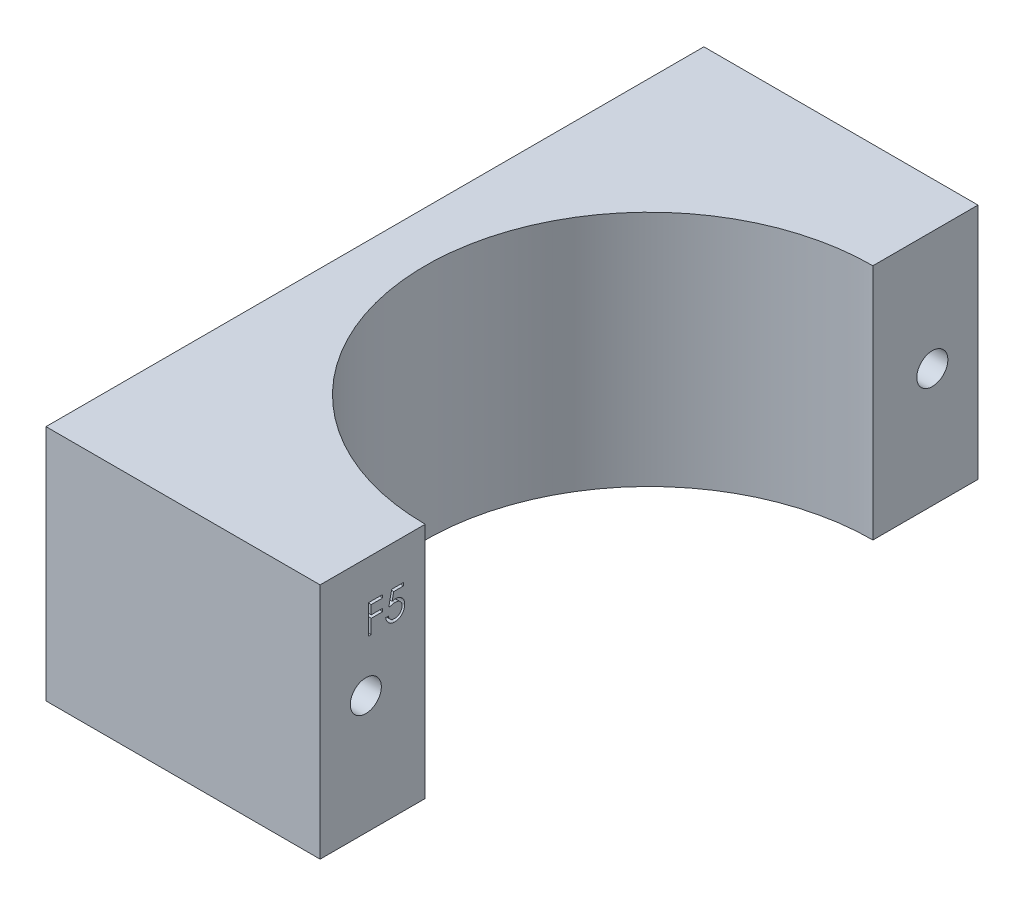
from build123d import *

# Parameters (mm, degrees)
BOSS_EXTRUDE1_DEPTH = 26
SKETCH2_R           = 1.7
CUT_EXTRUDE1_DEPTH  = 31
CUT_EXTRUDE2_DEPTH  = 1


with BuildPart() as part:
    # Sketch1 → Boss-Extrude1 (new body)
    with BuildSketch(Plane(origin=(0, 0, 0), x_dir=(1, 0, 0), z_dir=(0, 1, 0))):
        with BuildLine():
            Line((-46.998275301, 32.528571429), (-46.998275301, -39.471428571))
            Line((-46.998275301, -39.471428571), (-16.998275301, -39.471428571))
            Line((-16.998275301, -39.471428571), (-16.998275301, -27.971428571))
            ThreePointArc((-16.998275301, -27.971428571), (-41.498275301, -3.471428571), (-16.998275301, 21.028571429))
            Line((-16.998275301, 21.028571429), (-16.998275301, 32.528571429))
            Line((-16.998275301, 32.528571429), (-46.998275301, 32.528571429))
        make_face()
    extrude(amount=BOSS_EXTRUDE1_DEPTH)

    # Sketch2 → Cut-Extrude1 (cut, through all)
    with BuildSketch(Plane(origin=(-16.998275301, 0, 0), x_dir=(0, 0, -1), z_dir=(1, 0, 0))):
        with Locations((-34.471428571, 13)):
            Circle(SKETCH2_R)
        with Locations((27.528571429, 13)):
            Circle(SKETCH2_R)
    extrude(amount=-CUT_EXTRUDE1_DEPTH, mode=Mode.SUBTRACT)

    # Sketch3 → Cut-Extrude2 (cut)
    with BuildSketch(Plane(origin=(-16.998275301, 0, 0), x_dir=(0, 0, -1), z_dir=(1, 0, 0))):
        Polygon((-34.164231178, 21.664809495), (-32.617436306, 21.664809495), (-32.617436306, 21.33916847), (-33.87929528, 21.33916847), (-33.87929528, 20.362245393), (-32.617436306, 20.362245393), (-32.617436306, 20.036604367), (-33.87929528, 20.036604367), (-33.87929528, 18.489809495), (-34.164231178, 18.489809495), align=None)
        with BuildLine():
            Line((-30.337949127, 21.664809495), (-30.337949127, 21.33916847))
            Line((-30.337949127, 21.33916847), (-31.417271042, 21.33916847))
            Line((-31.417271042, 21.33916847), (-31.588995801, 20.504077324))
            add(Edge.make_bspline(
                [(-31.588995801, 20.504077324), (-31.555380829, 20.513357642), (-31.490257138, 20.53133679), (-31.394136407, 20.551299168), (-31.302884908, 20.563332821), (-31.243670822, 20.564975938), (-31.215017436, 20.565771034)],
                knots=[0, 0, 0, 0, 0.000104595, 0.000202637, 0.000294305, 0.000380252, 0.000380252, 0.000380252, 0.000380252], degree=3))
            add(Edge.make_bspline(
                [(-31.215017436, 20.565771034), (-31.179562901, 20.565003649), (-31.109850426, 20.56349478), (-31.007852238, 20.54900603), (-30.910485971, 20.526200536), (-30.817955249, 20.494341206), (-30.730088893, 20.453601662), (-30.647695319, 20.402711002), (-30.569537784, 20.343262909), (-30.497018431, 20.27491422), (-30.431228522, 20.199692467), (-30.37338366, 20.118813541), (-30.324250453, 20.033063448), (-30.284734626, 19.941622896), (-30.253180265, 19.845502806), (-30.232178099, 19.743691821), (-30.218192941, 19.637149598), (-30.216630491, 19.564301881), (-30.215833742, 19.527154247)],
                knots=[0, 0, 0, 0, 0.000106308, 0.000209029, 0.000308378, 0.000405929, 0.000502102, 0.000598312, 0.00069588, 0.000796219, 0.000896736, 0.000995218, 0.001094066, 0.001192613, 0.001293582, 0.001396995, 0.001504047, 0.001615439, 0.001615439, 0.001615439, 0.001615439], degree=3))
            add(Edge.make_bspline(
                [(-30.215833742, 19.527154247), (-30.21643706, 19.501280519), (-30.217635543, 19.449882723), (-30.223730262, 19.373551912), (-30.235464805, 19.298837056), (-30.251219812, 19.225728244), (-30.271669005, 19.154363885), (-30.296424075, 19.084539713), (-30.326719043, 19.01669032), (-30.359948934, 18.950173711), (-30.397365381, 18.886493637), (-30.438893027, 18.826940628), (-30.482767437, 18.770621315), (-30.529976408, 18.718139715), (-30.58095874, 18.669840691), (-30.635096995, 18.625437607), (-30.691959176, 18.584179543), (-30.752425003, 18.547741252), (-30.815147113, 18.51421057), (-30.881031281, 18.48670279), (-30.948577774, 18.462109668), (-31.018758768, 18.44250674), (-31.091415298, 18.427146494), (-31.16666713, 18.416713806), (-31.244119595, 18.409115181), (-31.296620499, 18.408639514), (-31.323140433, 18.408399239)],
                knots=[0, 0, 0, 0, 7.7636e-05, 0.000154223, 0.000229512, 0.000304362, 0.000378447, 0.000452077, 0.000526407, 0.000601214, 0.00067506, 0.000747747, 0.00081887, 0.000889121, 0.000959302, 0.001029336, 0.001099058, 0.00116985, 0.001240974, 0.00131221, 0.00138383, 0.001456517, 0.001530612, 0.001606437, 0.001684346, 0.001763871, 0.001763871, 0.001763871, 0.001763871], degree=3))
            add(Edge.make_bspline(
                [(-31.323140433, 18.408399239), (-31.354776297, 18.409025928), (-31.417016122, 18.410258864), (-31.508202636, 18.423157061), (-31.5959366, 18.441630042), (-31.679511763, 18.469421516), (-31.759677124, 18.504244276), (-31.835353446, 18.548255374), (-31.9084744, 18.598129276), (-31.976067462, 18.656985024), (-32.038801936, 18.721315679), (-32.094959984, 18.791127253), (-32.144974014, 18.865267533), (-32.188043113, 18.944096573), (-32.224780604, 19.02740724), (-32.253641343, 19.115511677), (-32.276935279, 19.207949537), (-32.286789954, 19.271588793), (-32.29179528, 19.303912059)],
                knots=[0, 0, 0, 0, 9.4843e-05, 0.000186593, 0.000275792, 0.000363484, 0.000450342, 0.000537514, 0.000625728, 0.000715478, 0.000805885, 0.000894984, 0.00098389, 0.001073836, 0.001164117, 0.001256635, 0.001351658, 0.001449737, 0.001449737, 0.001449737, 0.001449737], degree=3))
            Line((-32.29179528, 19.303912059), (-32.006859383, 19.303912059))
            add(Edge.make_bspline(
                [(-32.006859383, 19.303912059), (-31.999848477, 19.273634849), (-31.986373127, 19.215440369), (-31.956795055, 19.133678367), (-31.920631011, 19.060817357), (-31.877628495, 18.995893521), (-31.826329539, 18.939279645), (-31.767792128, 18.888827024), (-31.702162408, 18.843311014), (-31.629234264, 18.805371789), (-31.552296685, 18.773015134), (-31.471772144, 18.751468954), (-31.389853202, 18.736318858), (-31.334446394, 18.734802333), (-31.306603974, 18.734040265)],
                knots=[0, 0, 0, 0, 9.3172e-05, 0.000179081, 0.000260145, 0.000336703, 0.000411917, 0.000488562, 0.000568128, 0.000650923, 0.00073478, 0.000817953, 0.000900557, 0.000983994, 0.000983994, 0.000983994, 0.000983994], degree=3))
            add(Edge.make_bspline(
                [(-31.306603974, 18.734040265), (-31.279427385, 18.734784827), (-31.22591646, 18.736250878), (-31.14716613, 18.747534839), (-31.07113588, 18.764913493), (-30.998575921, 18.790921147), (-30.928216524, 18.822530284), (-30.861837461, 18.863093246), (-30.797518422, 18.909774834), (-30.737258616, 18.96325692), (-30.682068544, 19.022193714), (-30.633304062, 19.085219635), (-30.592685005, 19.152454203), (-30.558454778, 19.222733421), (-30.532462142, 19.29682754), (-30.513919252, 19.374389321), (-30.503030763, 19.455610338), (-30.501532907, 19.511008927), (-30.500769639, 19.539238582)],
                knots=[0, 0, 0, 0, 8.15e-05, 0.000160473, 0.000238226, 0.000315066, 0.000391338, 0.000469218, 0.000547964, 0.000629516, 0.000710512, 0.000789892, 0.000868102, 0.000945761, 0.001024012, 0.00110315, 0.001184644, 0.001269321, 0.001269321, 0.001269321, 0.001269321], degree=3))
            add(Edge.make_bspline(
                [(-30.500769639, 19.539238582), (-30.501366974, 19.564707299), (-30.502536172, 19.61455869), (-30.512088904, 19.687492256), (-30.528705015, 19.756501373), (-30.551768106, 19.821919285), (-30.581050231, 19.883807694), (-30.616833671, 19.94223047), (-30.659789968, 19.99641759), (-30.708859038, 20.046394406), (-30.762614547, 20.092517971), (-30.82198137, 20.13183725), (-30.885717161, 20.164915232), (-30.953054012, 20.193461202), (-31.025593599, 20.213963307), (-31.101899401, 20.229355603), (-31.182795415, 20.238259539), (-31.238104539, 20.239494967), (-31.266534864, 20.240130008)],
                knots=[0, 0, 0, 0, 7.6388e-05, 0.000149519, 0.000220172, 0.000288967, 0.000357247, 0.000425206, 0.000494043, 0.000564207, 0.000635056, 0.000706145, 0.000777268, 0.000850264, 0.000925136, 0.001002969, 0.001083601, 0.001168886, 0.001168886, 0.001168886, 0.001168886], degree=3))
            add(Edge.make_bspline(
                [(-31.266534864, 20.240130008), (-31.291144678, 20.239603329), (-31.3419577, 20.23851587), (-31.419901979, 20.230508977), (-31.50180947, 20.217591903), (-31.587366191, 20.199824378), (-31.676829081, 20.17657333), (-31.770009344, 20.14871089), (-31.8671029, 20.115398791), (-31.932523979, 20.090241712), (-31.966154255, 20.077309495)],
                knots=[0, 0, 0, 0, 7.3822e-05, 0.000152423, 0.000234822, 0.000322511, 0.00041445, 0.000512043, 0.000614219, 0.000722306, 0.000722306, 0.000722306, 0.000722306], degree=3))
            Line((-31.966154255, 20.077309495), (-31.640513229, 21.664809495))
            Line((-31.640513229, 21.664809495), (-30.337949127, 21.664809495))
        make_face()
    extrude(amount=-CUT_EXTRUDE2_DEPTH, mode=Mode.SUBTRACT)


solid = part.part
